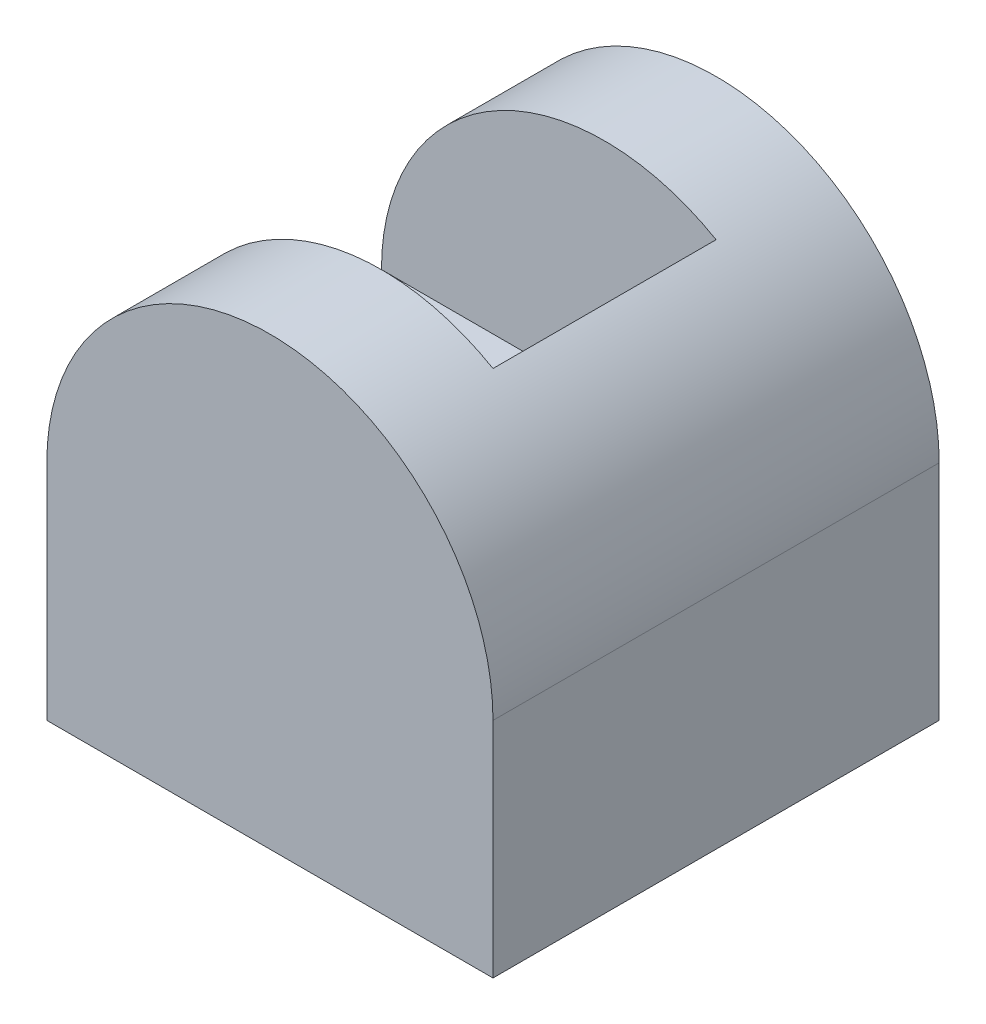
from build123d import *

# Parameters (mm, degrees)
SKETCH1_W           = 40
SKETCH1_H           = 40
BOSS_EXTRUDE1_DEPTH = 40
CUT_EXTRUDE1_DEPTH  = 40
CUT_EXTRUDE2_DEPTH  = 20
CUT_EXTRUDE3_DEPTH  = 30
BOSS_EXTRUDE2_DEPTH = 10
BOSS_EXTRUDE3_DEPTH = 20


with BuildPart() as part:
    # Sketch1 → Boss-Extrude1 (new body)
    with BuildSketch(Plane.XY):
        with Locations((20, 20)):
            Rectangle(SKETCH1_W, SKETCH1_H)
    extrude(amount=BOSS_EXTRUDE1_DEPTH)

    # Sketch2 → Cut-Extrude1 (cut)
    with BuildSketch(Plane.XY.offset(40)):
        with BuildLine():
            Line((0, 40), (0, 20))
            ThreePointArc((0, 20), (5.857864376, 34.142135624), (20, 40))
            Line((20, 40), (0, 40))
        make_face()
        with BuildLine():
            Line((40, 40), (20, 40))
            ThreePointArc((20, 40), (34.142135624, 34.142135624), (40, 20))
            Line((40, 20), (40, 40))
        make_face()
    extrude(amount=-CUT_EXTRUDE1_DEPTH, mode=Mode.SUBTRACT)

    # Sketch3 → Cut-Extrude2 (cut)
    with BuildSketch(Plane.XY.offset(10)):
        with BuildLine():
            Line((0, 20), (20, 20))
            Line((20, 20), (20, 40))
            ThreePointArc((20, 40), (5.857864376, 34.142135624), (0, 20))
        make_face()
    extrude(amount=CUT_EXTRUDE2_DEPTH, mode=Mode.SUBTRACT)

    # Sketch4 → Cut-Extrude3 (cut)
    with BuildSketch(Plane.XY.offset(40)):
        with BuildLine():
            Line((20, 20), (20, 40))
            ThreePointArc((20, 40), (27.653668647, 38.47759065), (34.142135624, 34.142135624))
            Line((34.142135624, 34.142135624), (20, 20))
        make_face()
    extrude(amount=-CUT_EXTRUDE3_DEPTH, mode=Mode.SUBTRACT)

    # Sketch5 → Boss-Extrude2 (add)
    with BuildSketch(Plane.XY.offset(40)):
        with BuildLine():
            Line((20, 40), (20, 20))
            Line((20, 20), (34.142135624, 34.142135624))
            ThreePointArc((34.142135624, 34.142135624), (27.653668647, 38.47759065), (20, 40))
        make_face()
    extrude(amount=-BOSS_EXTRUDE2_DEPTH)

    # Sketch6 → Boss-Extrude3 (add)
    with BuildSketch(Plane.XY.offset(10)):
        with BuildLine():
            Line((20, 20), (34.142135624, 34.142135624))
            ThreePointArc((34.142135624, 34.142135624), (32.17522858, 35.867066806), (30, 37.320508076))
            Line((30, 37.320508076), (20, 20))
        make_face()
    extrude(amount=BOSS_EXTRUDE3_DEPTH)


solid = part.part
